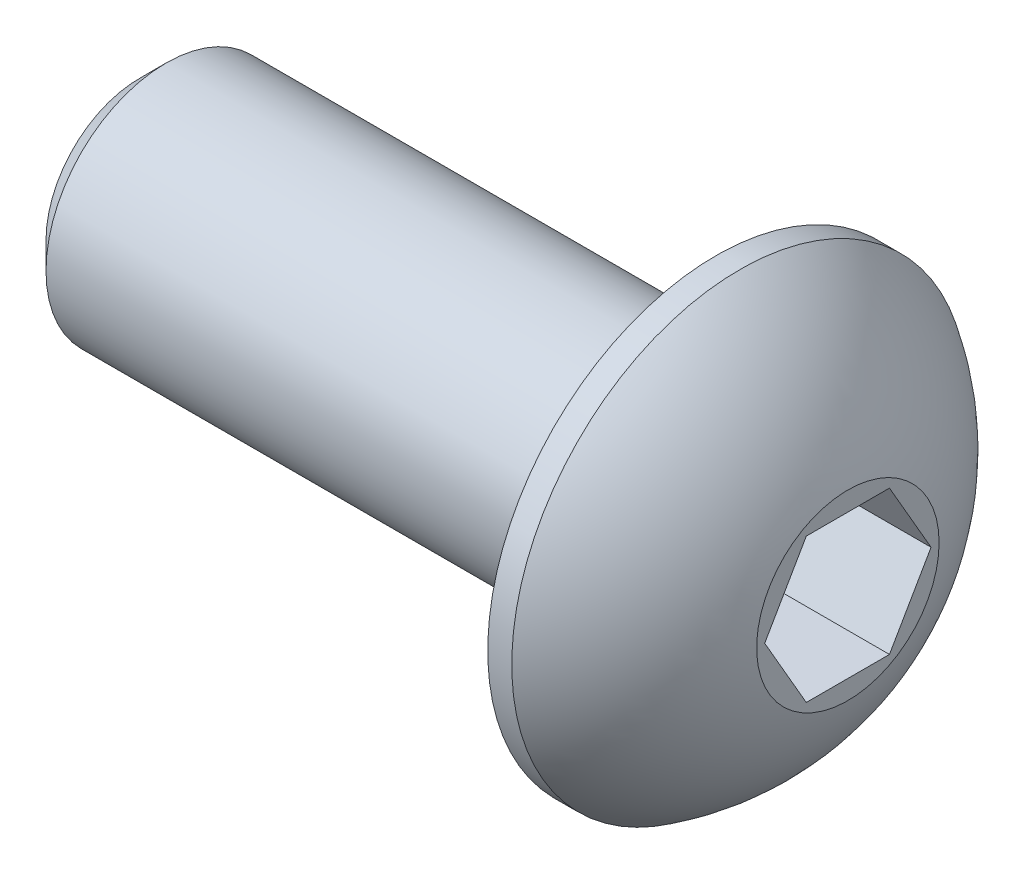
from build123d import *

# Parameters (mm, degrees)
SKETCH2_R           = 2.5
BOSS_EXTRUDE1_DEPTH = 12
CUT_EXTRUDE1_DEPTH  = 2.2
CHAMFER1_SIZE       = 0.55
CHAMFER2_SIZE       = 0.35
CHAMFER2_SIZE2      = 0.6


with BuildPart() as part:
    # Sketch1 → Revolve1 (revolve)
    with BuildSketch(Plane.XY.offset(9.9)):
        with BuildLine():
            Line((2.4, 14.65), (2.4, 9.9))
            Line((2.4, 9.9), (5.15, 9.9))
            Line((5.15, 9.9), (5.15, 11.8))
            ThreePointArc((5.15, 11.8), (4.281848259, 13.427774941), (2.899999999, 14.65))
            Line((2.899999999, 14.65), (2.4, 14.65))
        make_face()
    revolve(axis=Axis((2.4, 9.9, 9.9), (1, 0, 0)))

    # Sketch2 → Boss-Extrude1 (add)
    with BuildSketch(Plane.ZY.offset(-2.4)):
        with Locations((9.9, 9.9)):
            Circle(SKETCH2_R)
    extrude(amount=BOSS_EXTRUDE1_DEPTH)

    # Sketch3 → Cut-Extrude1 (cut)
    with BuildSketch(Plane(origin=(5.15, 0, 0), x_dir=(0, 0, -1), z_dir=(1, 0, 0))):
        Polygon((-11.6320508, 9.9), (-10.766025397, 8.400000002), (-9.033974587, 8.400000002), (-8.167949184, 9.9), (-9.033974587, 11.399999998), (-10.766025397, 11.399999998), align=None)
    extrude(amount=-CUT_EXTRUDE1_DEPTH, mode=Mode.SUBTRACT)

    # Chamfer1
    chamfer1_edges = [part.edges().sort_by_distance(p)[0] for p in [
        (-9.6, 9.9, 7.4),
    ]]
    chamfer(chamfer1_edges, length=CHAMFER1_SIZE)

    # Chamfer2
    chamfer2_edges = [part.edges().sort_by_distance(p)[0] for p in [
        (2.4, 9.9, 7.4),
    ]]
    chamfer2_side = [part.faces().sort_by_distance(p)[0] for p in [
        (2.4, 5.284350289, 9.9),
    ]]
    chamfer(chamfer2_edges, length=CHAMFER2_SIZE, length2=CHAMFER2_SIZE2, reference=chamfer2_side[0])


solid = part.part
